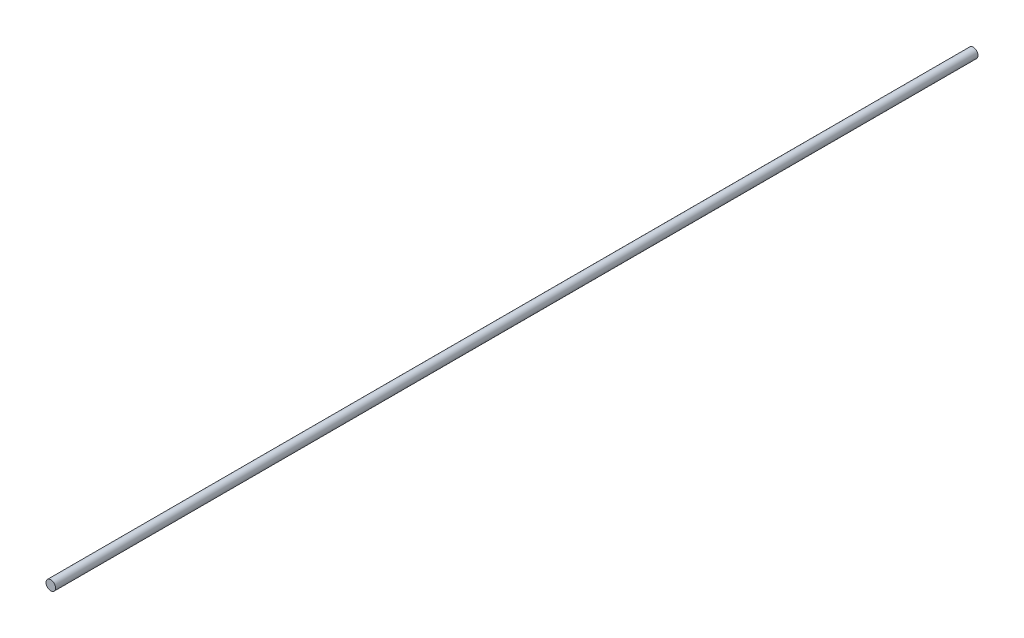
from build123d import *

# Parameters (mm, degrees)
SKETCH1_R           = 4.7625
BOSS_EXTRUDE1_DEPTH = 914.4


with BuildPart() as part:
    # Sketch1 → Boss-Extrude1 (new body)
    with BuildSketch(Plane.XY):
        Circle(SKETCH1_R)
    extrude(amount=BOSS_EXTRUDE1_DEPTH)


solid = part.part
